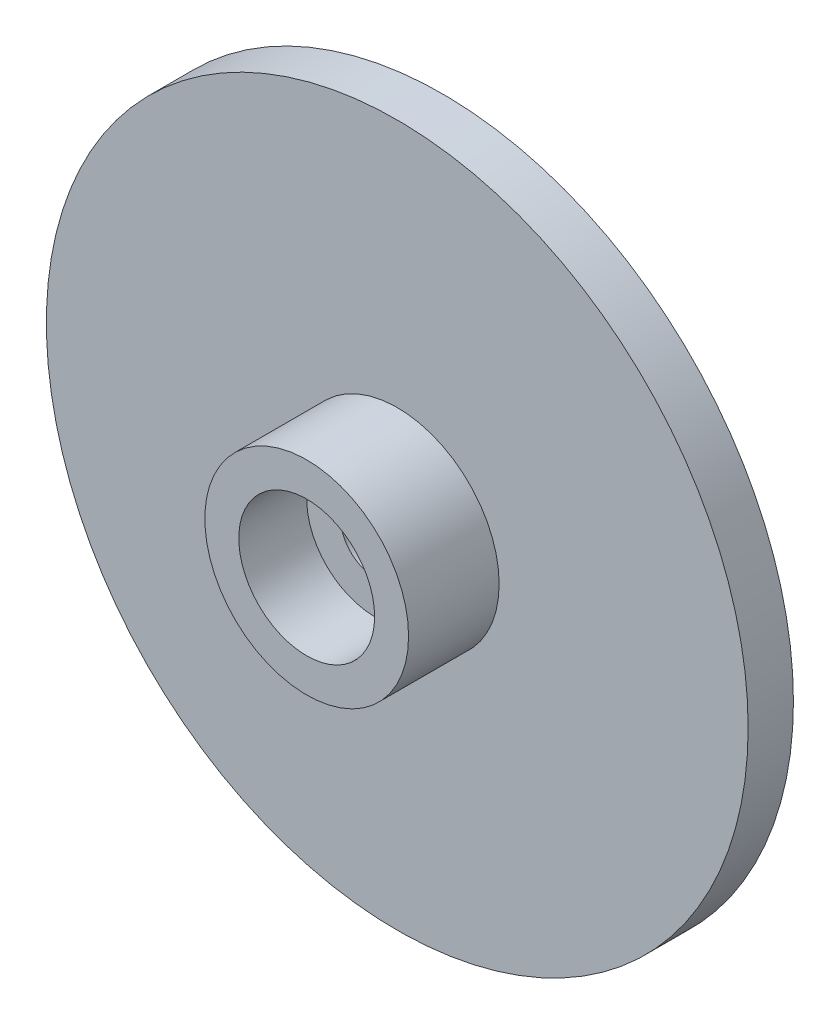
from build123d import *

# Parameters (mm, degrees)
SCHIZZO1_R                   = 15.5
ESTRUSIONE_ESTRUSIONE1_DEPTH = 2
SCHIZZO2_R                   = 4.5
SCHIZZO2_R_2                 = 3
ESTRUSIONE_ESTRUSIONE2_DEPTH = 4
SCHIZZO3_R                   = 3
ESTRUSIONE_ESTRUSIONE3_DEPTH = 1
SCHIZZO4_R                   = 4.5
SCHIZZO4_R_2                 = 3.5
SCHIZZO4_R_3                 = 3
TAGLIO_ESTRUSIONE1_DEPTH     = 1
SCHIZZO5_R                   = 1.5
TAGLIO_ESTRUSIONE2_DEPTH     = 12


with BuildPart() as part:
    # Schizzo1 → Estrusione-Estrusione1 (new body)
    with BuildSketch(Plane.XY):
        Circle(SCHIZZO1_R)
    extrude(amount=ESTRUSIONE_ESTRUSIONE1_DEPTH)

    # Schizzo2 → Estrusione-Estrusione2 (add)
    with BuildSketch(Plane.XY.offset(2)):
        Circle(SCHIZZO2_R)
        Circle(SCHIZZO2_R_2, mode=Mode.SUBTRACT)
    extrude(amount=ESTRUSIONE_ESTRUSIONE2_DEPTH)

    # Schizzo3 → Estrusione-Estrusione3 (add)
    with BuildSketch(Plane.XY.offset(2)):
        Circle(SCHIZZO3_R)
    extrude(amount=ESTRUSIONE_ESTRUSIONE3_DEPTH)

    # Schizzo4 → Taglio-Estrusione1 (cut)
    with BuildSketch(Plane(origin=(0, 0, 0), x_dir=(-1, 0, 0), z_dir=(0, 0, -1))):
        with Locations(Location((0, 0, 0), (0, 0, 180))):
            Circle(SCHIZZO4_R)
        Circle(SCHIZZO4_R_2, mode=Mode.SUBTRACT)
        with Locations(Location((0, 0, 0), (0, 0, 180))):
            Circle(SCHIZZO4_R_3)
    extrude(amount=-TAGLIO_ESTRUSIONE1_DEPTH, mode=Mode.SUBTRACT)

    # Schizzo5 → Taglio-Estrusione2 (cut)
    with BuildSketch(Plane(origin=(0, 0, 1), x_dir=(-1, 0, 0), z_dir=(0, 0, -1))):
        Circle(SCHIZZO5_R)
    extrude(amount=-TAGLIO_ESTRUSIONE2_DEPTH, mode=Mode.SUBTRACT)


solid = part.part
